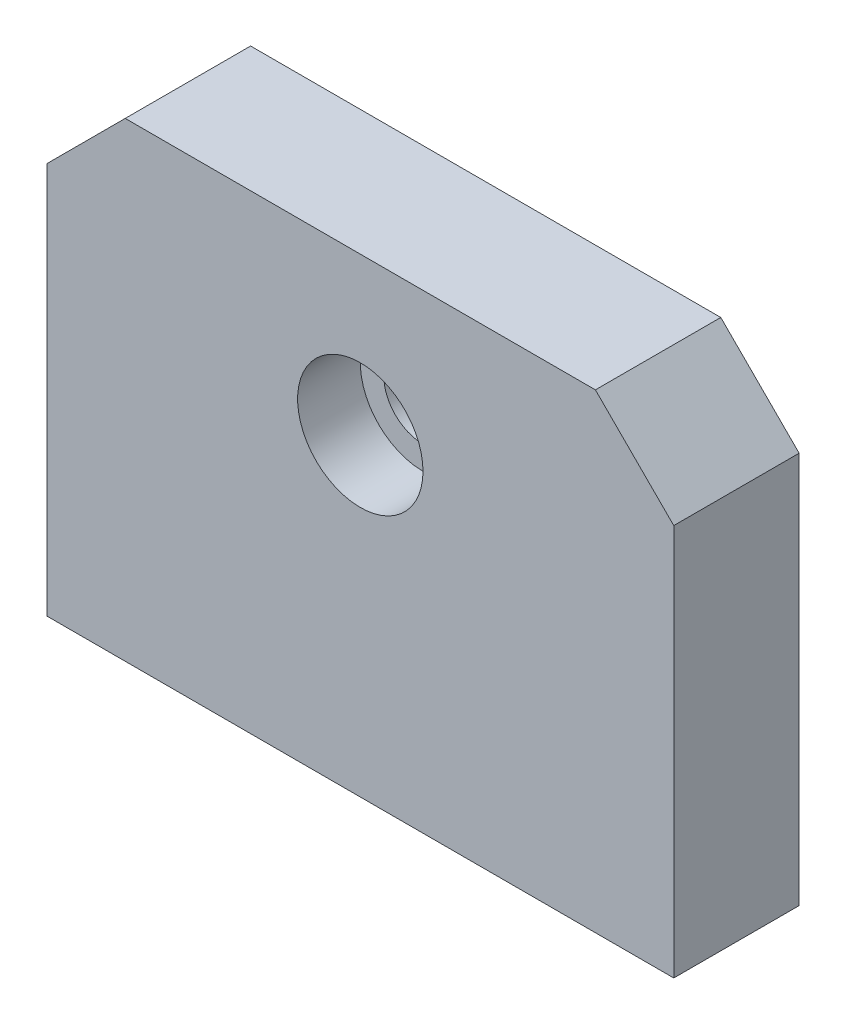
from build123d import *

# Parameters (mm, degrees)
ESQUISSE1_R      = 2.5
EXTRUSION1_DEPTH = 8
ESQUISSE2_R      = 4
EXTRUSION2_DEPTH = 4
ESQUISSE3_R      = 2
EXTRUSION3_DEPTH = 15


with BuildPart() as part:
    # Esquisse1 → Extrusion1 (new body)
    with BuildSketch(Plane.XY):
        Polygon((-20, -20), (-20, 5), (-15, 10), (15, 10), (20, 5), (20, -20), align=None)
        Circle(ESQUISSE1_R, mode=Mode.SUBTRACT)
    extrude(amount=EXTRUSION1_DEPTH)

    # Esquisse2 → Extrusion2 (cut)
    with BuildSketch(Plane.XY.offset(8)):
        Circle(ESQUISSE2_R)
    extrude(amount=-EXTRUSION2_DEPTH, mode=Mode.SUBTRACT)

    # Esquisse3 → Extrusion3 (cut)
    with BuildSketch(Plane.XZ.offset(20)):
        with Locations((-15.5, 4)):
            Circle(ESQUISSE3_R)
        with Locations((15.5, 4)):
            Circle(ESQUISSE3_R)
    extrude(amount=-EXTRUSION3_DEPTH, mode=Mode.SUBTRACT)


solid = part.part
